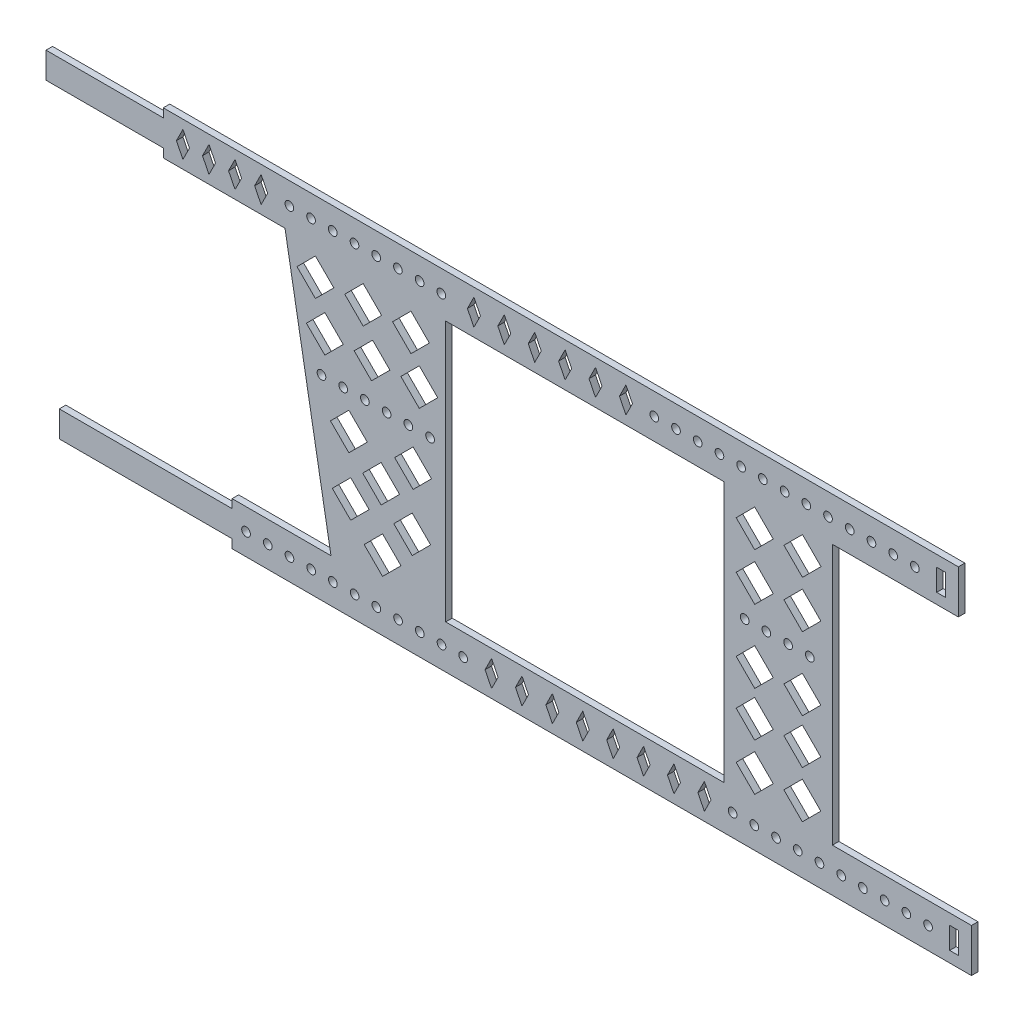
from build123d import *

# Parameters (mm, degrees)
SKETCH_1_R      = 1
SKETCH_1_W      = 2
SKETCH_1_H      = 5
SKETCH_1_W_2    = 64.030489503
SKETCH_1_H_2    = 60
EXTRUDE_1_DEPTH = 1.5


with BuildPart() as part:
    # 草图1 → 凸台-拉伸1 (new body)
    with BuildSketch(Plane.XY):
        Polygon((-91.030495968, 5.035282886), (-91.030495968, 3.035282886), (-118.030495968, 3.035282886), (-118.030495968, -2.964717114), (-91.030495968, -2.964717114), (-91.030495968, -4.964717114), (-62.999893355, -4.964717114), (-52.420274512, -64.964717114), (-75.17096147, -64.964717114), (-75.17096147, -66.964717114), (-114.969403852, -66.964717114), (-114.969403852, -72.964717114), (-75.17096147, -72.964717114), (-75.17096147, -74.964717114), (95.064627116, -74.964717114), (95.064627116, -64.964717114), (63.030596148, -64.964717114), (63.030596148, -4.964717114), (92.030596148, -4.964717114), (92.030596148, 5.035282886), align=None)
        with Locations((-71.969403852, -69.964717114)):
            Circle(SKETCH_1_R, mode=Mode.SUBTRACT)
        with Locations((-66.969403852, -69.964717114)):
            Circle(SKETCH_1_R, mode=Mode.SUBTRACT)
        with Locations((-61.969403852, -69.964717114)):
            Circle(SKETCH_1_R, mode=Mode.SUBTRACT)
        with Locations((-56.969403852, -69.964717114)):
            Circle(SKETCH_1_R, mode=Mode.SUBTRACT)
        with Locations((-51.969403852, -69.964717114)):
            Circle(SKETCH_1_R, mode=Mode.SUBTRACT)
        with Locations((-46.969403852, -69.964717114)):
            Circle(SKETCH_1_R, mode=Mode.SUBTRACT)
        with Locations((-41.969403852, -69.964717114)):
            Circle(SKETCH_1_R, mode=Mode.SUBTRACT)
        Polygon((-15.435372884, -66.966180231), (-13.935372884, -69.966187781), (-15.435372884, -72.966195331), (-16.935372884, -69.966187781), align=None, mode=Mode.SUBTRACT)
        with Locations((-36.969403852, -69.964717114)):
            Circle(SKETCH_1_R, mode=Mode.SUBTRACT)
        with Locations((-31.969403852, -69.964717114)):
            Circle(SKETCH_1_R, mode=Mode.SUBTRACT)
        with Locations((-26.969403852, -69.964717114)):
            Circle(SKETCH_1_R, mode=Mode.SUBTRACT)
        with Locations((-21.969403852, -69.964717114)):
            Circle(SKETCH_1_R, mode=Mode.SUBTRACT)
        Polygon((-44.780702844, -58.918058275), (-40.538062157, -54.675417588), (-36.29542147, -58.918058275), (-40.538062157, -63.160698962), align=None, mode=Mode.SUBTRACT)
        Polygon((-52.114588356, -51.383697663), (-47.871947669, -47.141056976), (-43.629306982, -51.383697663), (-47.871947669, -55.62633835), align=None, mode=Mode.SUBTRACT)
        Polygon((-37.95128426, -51.345378073), (-33.708643573, -47.102737386), (-29.466002886, -51.345378073), (-33.708643573, -55.58801876), align=None, mode=Mode.SUBTRACT)
        Polygon((-45.106332508, -44.847494945), (-40.863691821, -40.604854258), (-36.621051134, -44.847494945), (-40.863691821, -49.090135632), align=None, mode=Mode.SUBTRACT)
        Polygon((-52.536676588, -38.141926095), (-48.294035901, -33.899285408), (-44.051395214, -38.141926095), (-48.294035901, -42.384566782), align=None, mode=Mode.SUBTRACT)
        Polygon((-37.748086888, -38.065793199), (-33.505446201, -33.823152512), (-29.262805514, -38.065793199), (-33.505446201, -42.308433886), align=None, mode=Mode.SUBTRACT)
        Polygon((-8.435372884, -72.966195331), (-9.935372884, -69.966187781), (-8.435372884, -66.966180231), (-6.935372884, -69.966187781), align=None, mode=Mode.SUBTRACT)
        Polygon((-1.435372884, -72.966195331), (-2.935372884, -69.966187781), (-1.435372884, -66.966180231), (0.064627116, -69.966187781), align=None, mode=Mode.SUBTRACT)
        Polygon((5.564627116, -72.966195331), (4.064627116, -69.966187781), (5.564627116, -66.966180231), (7.064627116, -69.966187781), align=None, mode=Mode.SUBTRACT)
        Polygon((12.564627116, -72.966195331), (11.064627116, -69.966187781), (12.564627116, -66.966180231), (14.064627116, -69.966187781), align=None, mode=Mode.SUBTRACT)
        Polygon((19.564627116, -72.966195331), (18.064627116, -69.966187781), (19.564627116, -66.966180231), (21.064627116, -69.966187781), align=None, mode=Mode.SUBTRACT)
        Polygon((26.564627116, -72.966195331), (25.064627116, -69.966187781), (26.564627116, -66.966180231), (28.064627116, -69.966187781), align=None, mode=Mode.SUBTRACT)
        Polygon((33.564627116, -72.966195331), (32.064627116, -69.966187781), (33.564627116, -66.966180231), (35.064627116, -69.966187781), align=None, mode=Mode.SUBTRACT)
        with Locations((40.064627116, -69.964717114)):
            Circle(SKETCH_1_R, mode=Mode.SUBTRACT)
        with Locations((45.064627116, -69.964717114)):
            Circle(SKETCH_1_R, mode=Mode.SUBTRACT)
        with Locations((50.064627116, -69.964717114)):
            Circle(SKETCH_1_R, mode=Mode.SUBTRACT)
        with Locations((55.064627116, -69.964717114)):
            Circle(SKETCH_1_R, mode=Mode.SUBTRACT)
        with Locations((60.064627116, -69.964717114)):
            Circle(SKETCH_1_R, mode=Mode.SUBTRACT)
        with Locations((65.064627116, -69.964717114)):
            Circle(SKETCH_1_R, mode=Mode.SUBTRACT)
        with Locations((70.064627116, -69.964717114)):
            Circle(SKETCH_1_R, mode=Mode.SUBTRACT)
        with Locations((75.064627116, -69.964717114)):
            Circle(SKETCH_1_R, mode=Mode.SUBTRACT)
        with Locations((80.064627116, -69.964717114)):
            Circle(SKETCH_1_R, mode=Mode.SUBTRACT)
        with Locations((85.064627116, -69.964717114)):
            Circle(SKETCH_1_R, mode=Mode.SUBTRACT)
        with Locations((91.041377623, -69.946785938)):
            Rectangle(SKETCH_1_W, SKETCH_1_H, mode=Mode.SUBTRACT)
        Polygon((40.877840935, -59.522953409), (45.145983497, -55.254810846), (49.41412606, -59.522953409), (45.145983497, -63.791095971), align=None, mode=Mode.SUBTRACT)
        Polygon((51.865089997, -59.510202471), (56.120481622, -55.254810846), (60.375873246, -59.510202471), (56.120481622, -63.765594096), align=None, mode=Mode.SUBTRACT)
        Polygon((40.87382717, -48.72025407), (45.141969733, -44.452111507), (49.410112295, -48.72025407), (45.141969733, -52.988396632), align=None, mode=Mode.SUBTRACT)
        Polygon((51.861076232, -48.707503132), (56.116467857, -44.452111507), (60.371859482, -48.707503132), (56.116467857, -52.962894757), align=None, mode=Mode.SUBTRACT)
        Polygon((40.887199733, -38.383165413), (45.155342296, -34.115022851), (49.423484858, -38.383165413), (45.155342296, -42.651307976), align=None, mode=Mode.SUBTRACT)
        Polygon((51.887199733, -38.383165413), (56.12984042, -34.140524726), (60.372481107, -38.383165413), (56.12984042, -42.6258061), align=None, mode=Mode.SUBTRACT)
        with Locations((-54.598317058, -29.99999245)):
            Circle(SKETCH_1_R, mode=Mode.SUBTRACT)
        with Locations((-49.598317058, -29.99999245)):
            Circle(SKETCH_1_R, mode=Mode.SUBTRACT)
        with Locations((-44.598317058, -29.99999245)):
            Circle(SKETCH_1_R, mode=Mode.SUBTRACT)
        with Locations((-39.598317058, -29.99999245)):
            Circle(SKETCH_1_R, mode=Mode.SUBTRACT)
        with Locations((-34.598317058, -29.99999245)):
            Circle(SKETCH_1_R, mode=Mode.SUBTRACT)
        with Locations((-29.598317058, -29.99999245)):
            Circle(SKETCH_1_R, mode=Mode.SUBTRACT)
        Polygon((-58.070528094, -21.436133175), (-53.827887407, -17.193492488), (-49.58524672, -21.436133175), (-53.827887407, -25.678773862), align=None, mode=Mode.SUBTRACT)
        Polygon((-47.070528094, -21.436133175), (-42.827887407, -17.193492488), (-38.839924125, -21.18145577), (-43.082564812, -25.424096457), align=None, mode=Mode.SUBTRACT)
        Polygon((-36.325205499, -21.18145577), (-32.082564812, -16.938815083), (-27.839924125, -21.18145577), (-32.082564812, -25.424096457), align=None, mode=Mode.SUBTRACT)
        Polygon((-86.499995574, 3.00021954), (-84.999893355, 7.55e-06), (-85.000048897, -0.000303535), (-86.499946677, -3.000106646), (-88.000048897, 0.000105344), align=None, mode=Mode.SUBTRACT)
        Polygon((-80.499946677, -3.000106646), (-82.000048897, 0.000105344), (-80.499995574, 3.00021954), (-78.999893355, 7.55e-06), align=None, mode=Mode.SUBTRACT)
        Polygon((-74.499946677, -3.000106646), (-76.000048897, 0.000105344), (-74.499995574, 3.00021954), (-72.999893355, 7.55e-06), align=None, mode=Mode.SUBTRACT)
        Polygon((-68.499946677, -3.000106646), (-70.000048897, 0.000105344), (-68.499995574, 3.00021954), (-66.999893355, 7.55e-06), align=None, mode=Mode.SUBTRACT)
        Polygon((-60.241215598, -11.234867157), (-55.998574911, -6.99222647), (-51.755934224, -11.234867157), (-55.998574911, -15.477507844), align=None, mode=Mode.SUBTRACT)
        Polygon((-49.241215598, -11.234867157), (-44.998574911, -6.99222647), (-40.755934224, -11.234867157), (-44.998574911, -15.477507844), align=None, mode=Mode.SUBTRACT)
        Polygon((-38.241215598, -11.234867157), (-33.998574911, -6.99222647), (-29.755934224, -11.234867157), (-33.998574911, -15.477507844), align=None, mode=Mode.SUBTRACT)
        with Locations((-61.999893355, 7.55e-06)):
            Circle(SKETCH_1_R, mode=Mode.SUBTRACT)
        with Locations((-56.999893355, 7.55e-06)):
            Circle(SKETCH_1_R, mode=Mode.SUBTRACT)
        with Locations((-51.999893355, 7.55e-06)):
            Circle(SKETCH_1_R, mode=Mode.SUBTRACT)
        with Locations((-46.999893355, 7.55e-06)):
            Circle(SKETCH_1_R, mode=Mode.SUBTRACT)
        with Locations((-41.999893355, 7.55e-06)):
            Circle(SKETCH_1_R, mode=Mode.SUBTRACT)
        with Locations((-36.999893355, 7.55e-06)):
            Circle(SKETCH_1_R, mode=Mode.SUBTRACT)
        with Locations((-31.999893355, 7.55e-06)):
            Circle(SKETCH_1_R, mode=Mode.SUBTRACT)
        with Locations((-26.999893355, 7.55e-06)):
            Circle(SKETCH_1_R, mode=Mode.SUBTRACT)
        Polygon((-19.499994314, -2.960033292), (-20.999994314, 0.039974259), (-19.499994314, 3.039981809), (-17.999994314, 0.039974259), align=None, mode=Mode.SUBTRACT)
        Polygon((-12.499994314, -2.960033292), (-13.999994314, 0.039974259), (-12.499994314, 3.039981809), (-10.999994314, 0.039974259), align=None, mode=Mode.SUBTRACT)
        with Locations((6.015351396, -34.964717114)):
            Rectangle(SKETCH_1_W_2, SKETCH_1_H_2, mode=Mode.SUBTRACT)
        with Locations((42.844614024, -29.964205592)):
            Circle(SKETCH_1_R, mode=Mode.SUBTRACT)
        with Locations((47.844614024, -29.964205592)):
            Circle(SKETCH_1_R, mode=Mode.SUBTRACT)
        with Locations((52.844614024, -29.964205592)):
            Circle(SKETCH_1_R, mode=Mode.SUBTRACT)
        with Locations((57.844614024, -29.964205592)):
            Circle(SKETCH_1_R, mode=Mode.SUBTRACT)
        Polygon((40.888975631, -21.619966166), (45.157118193, -17.351823604), (49.425260756, -21.619966166), (45.157118193, -25.888108729), align=None, mode=Mode.SUBTRACT)
        Polygon((51.876224693, -21.607215228), (56.131616318, -17.351823604), (60.387007942, -21.607215228), (56.131616318, -25.862606853), align=None, mode=Mode.SUBTRACT)
        Polygon((-5.499994314, -2.960033292), (-6.999994314, 0.039974259), (-5.499994314, 3.039981809), (-3.999994314, 0.039974259), align=None, mode=Mode.SUBTRACT)
        Polygon((1.500005686, -2.960033292), (5.686e-06, 0.039974259), (1.500005686, 3.039981809), (3.000005686, 0.039974259), align=None, mode=Mode.SUBTRACT)
        Polygon((8.500005686, -2.960033292), (7.000005686, 0.039974259), (8.500005686, 3.039981809), (10.000005686, 0.039974259), align=None, mode=Mode.SUBTRACT)
        with Locations((22.030596148, 0.033051711)):
            Circle(SKETCH_1_R, mode=Mode.SUBTRACT)
        with Locations((27.030596148, 0.033051711)):
            Circle(SKETCH_1_R, mode=Mode.SUBTRACT)
        with Locations((32.030596148, 0.033051711)):
            Circle(SKETCH_1_R, mode=Mode.SUBTRACT)
        with Locations((37.030596148, 0.033051711)):
            Circle(SKETCH_1_R, mode=Mode.SUBTRACT)
        Polygon((15.500005686, -2.960033292), (14.000005686, 0.039974259), (15.500005686, 3.039981809), (17.000005686, 0.039974259), align=None, mode=Mode.SUBTRACT)
        Polygon((40.881123238, -10.736981843), (45.149265801, -6.46883928), (49.417408363, -10.736981843), (45.149265801, -15.005124406), align=None, mode=Mode.SUBTRACT)
        Polygon((51.881123238, -10.736981843), (56.149265801, -6.46883928), (60.417408363, -10.736981843), (56.149265801, -15.005124406), align=None, mode=Mode.SUBTRACT)
        with Locations((42.030596148, 0.033051711)):
            Circle(SKETCH_1_R, mode=Mode.SUBTRACT)
        with Locations((47.030596148, 0.033051711)):
            Circle(SKETCH_1_R, mode=Mode.SUBTRACT)
        with Locations((52.030596148, 0.033051711)):
            Circle(SKETCH_1_R, mode=Mode.SUBTRACT)
        with Locations((57.030596148, 0.033051711)):
            Circle(SKETCH_1_R, mode=Mode.SUBTRACT)
        with Locations((62.030596148, 0.033051711)):
            Circle(SKETCH_1_R, mode=Mode.SUBTRACT)
        with Locations((67.030596148, 0.033051711)):
            Circle(SKETCH_1_R, mode=Mode.SUBTRACT)
        with Locations((72.030596148, 0.033051711)):
            Circle(SKETCH_1_R, mode=Mode.SUBTRACT)
        with Locations((77.030596148, 0.033051711)):
            Circle(SKETCH_1_R, mode=Mode.SUBTRACT)
        with Locations((82.030596148, 0.033051711)):
            Circle(SKETCH_1_R, mode=Mode.SUBTRACT)
        with Locations((88.047998971, -0.042432984)):
            Rectangle(SKETCH_1_W, SKETCH_1_H, mode=Mode.SUBTRACT)
    extrude(amount=EXTRUDE_1_DEPTH)


solid = part.part
